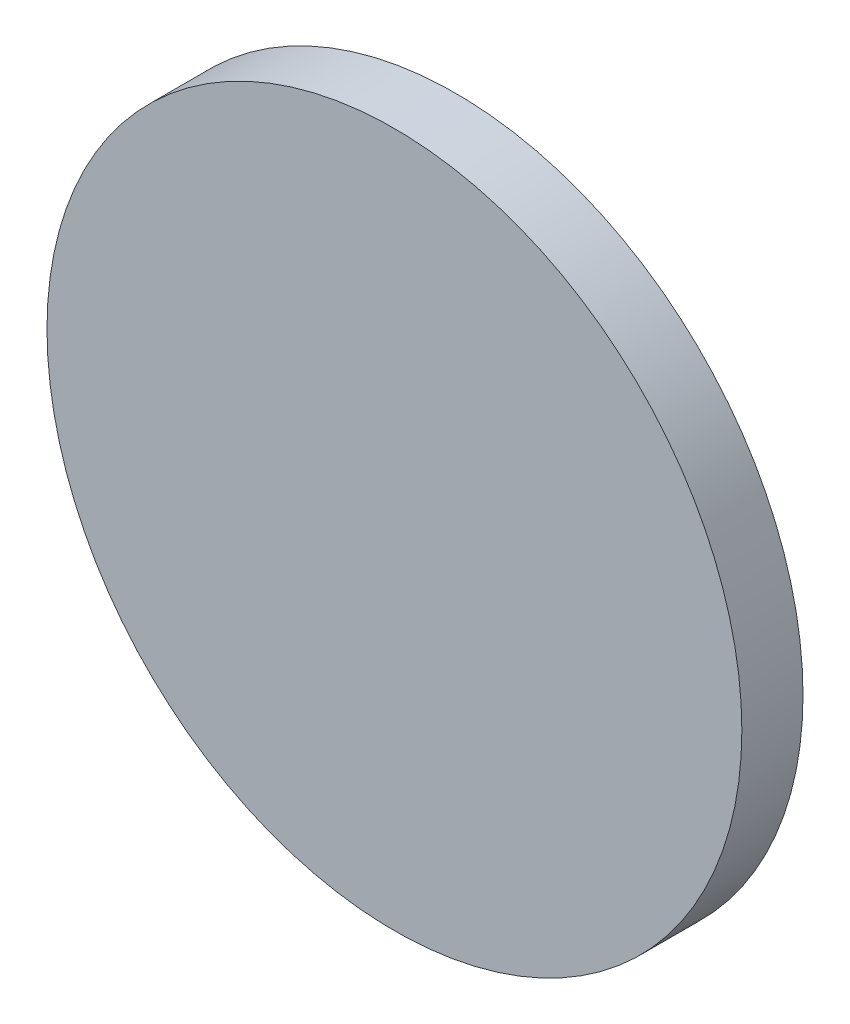
from build123d import *

# Parameters (mm, degrees)
SKETCH_1_R      = 6.25
EXTRUDE_1_DEPTH = 1.1


with BuildPart() as part:
    # 草图1 → 凸台-拉伸1 (new body)
    with BuildSketch(Plane.XY):
        Circle(SKETCH_1_R)
    extrude(amount=EXTRUDE_1_DEPTH)


solid = part.part
